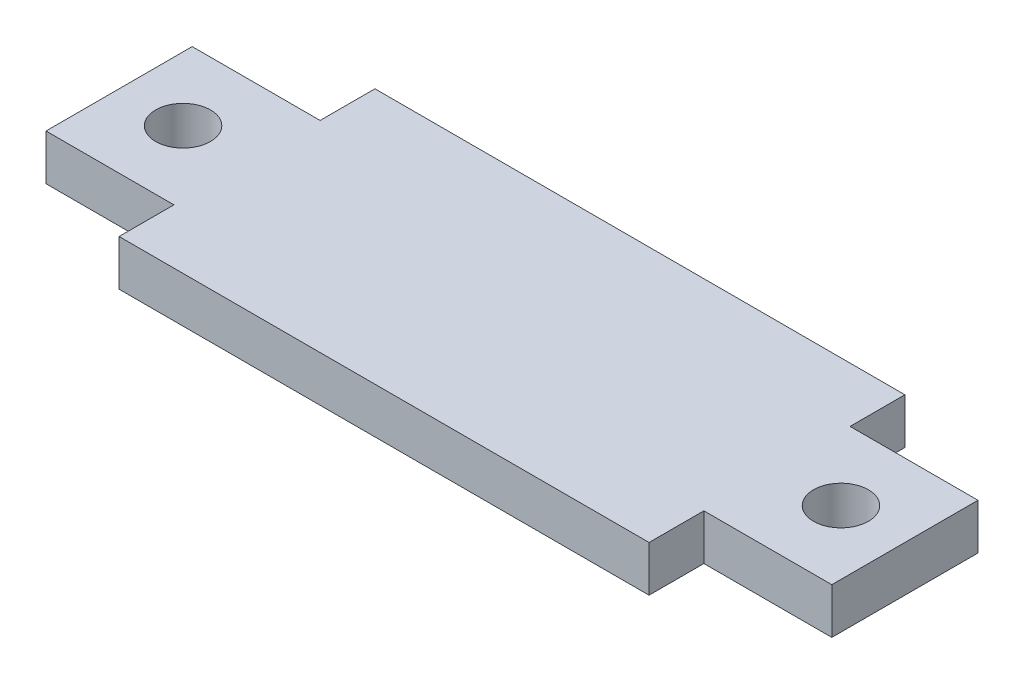
from build123d import *

# Parameters (mm, degrees)
SKETCH1_W           = 29
SKETCH1_H           = 14
SKETCH1_W_2         = 7
SKETCH1_H_2         = 8
SKETCH1_R           = 1.5
BOSS_EXTRUDE1_DEPTH = 2.5


with BuildPart() as part:
    # Sketch1 → Boss-Extrude1 (new body)
    with BuildSketch(Plane(origin=(0, 0, 0), x_dir=(1, 0, 0), z_dir=(0, 1, 0))):
        Rectangle(SKETCH1_W, SKETCH1_H)
        with Locations((-18, 0)):
            Rectangle(SKETCH1_W_2, SKETCH1_H_2)
        with Locations((-18, 0)):
            Circle(SKETCH1_R, mode=Mode.SUBTRACT)
        with Locations((18, 0)):
            Rectangle(SKETCH1_W_2, SKETCH1_H_2)
        with Locations((18, 0)):
            Circle(SKETCH1_R, mode=Mode.SUBTRACT)
    extrude(amount=BOSS_EXTRUDE1_DEPTH)


solid = part.part
